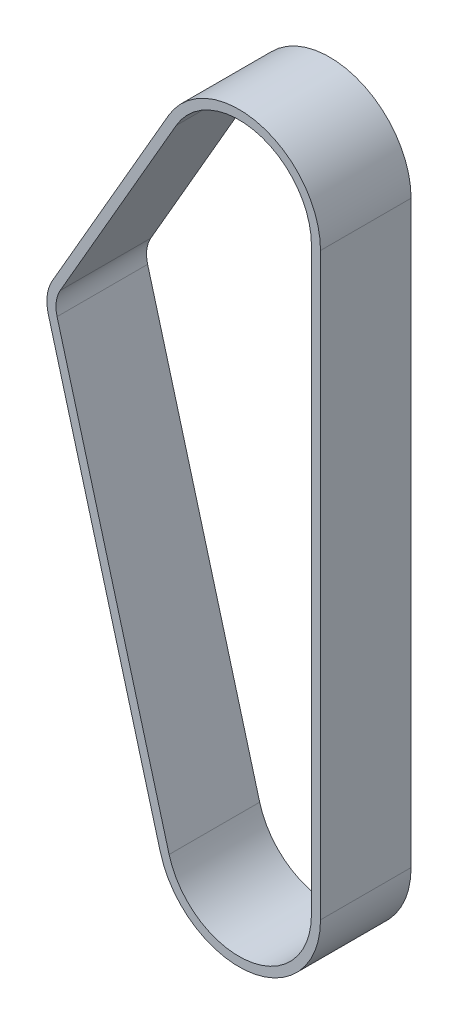
from build123d import *

# Parameters (mm, degrees)
BOSS_EXTRUDE1_DEPTH = 50


with BuildPart() as part:
    # Sketch1 → Boss-Extrude1 (new body)
    with BuildSketch(Plane.XY):
        with BuildLine():
            Line((-103.035571585, 231.537155028), (-38.97114317, 342.5))
            ThreePointArc((-38.97114317, 342.5), (11.64685703, 363.466662183), (45, 320))
            Line((45, 320), (45, 0))
            ThreePointArc((45, 0), (5.986745133, -44.599987474), (-43.407061454, -11.867055908))
            Line((-43.407061454, -11.867055908), (-105.253530727, 214.353627074))
            ThreePointArc((-105.253530727, 214.353627074), (-105.864881706, 223.167442243), (-103.035571585, 231.537155028))
        make_face()
        with BuildLine():
            Line((40, 320), (40, 0))
            ThreePointArc((40, 0), (5.321551229, -39.644433311), (-38.584054626, -10.54849414))
            Line((-38.584054626, -10.54849414), (-100.430523899, 215.672188841))
            ThreePointArc((-100.430523899, 215.672188841), (-100.906019105, 222.527378417), (-98.705444566, 229.037155028))
            Line((-98.705444566, 229.037155028), (-34.641016151, 340))
            ThreePointArc((-34.641016151, 340), (10.352761804, 358.637033052), (40, 320))
        make_face(mode=Mode.SUBTRACT)
    extrude(amount=BOSS_EXTRUDE1_DEPTH)


solid = part.part
